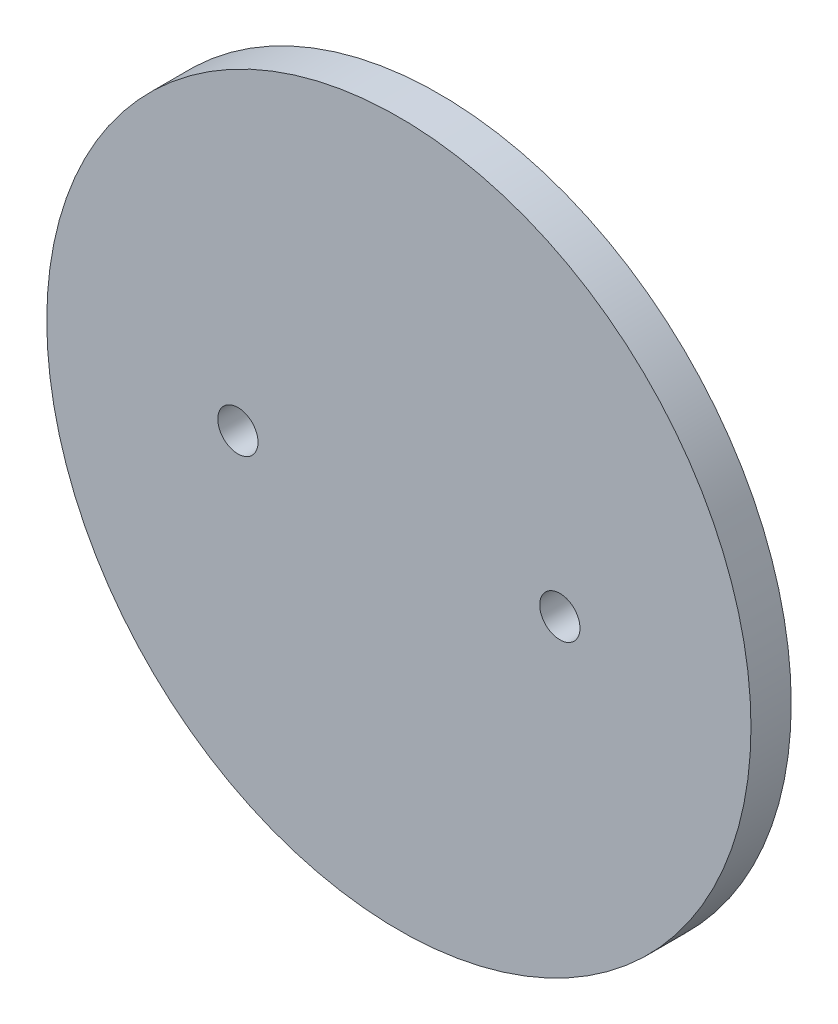
from build123d import *

# Parameters (mm, degrees)
SKETCH1_R           = 22.225
BOSS_EXTRUDE1_DEPTH = 2.54
CUT_EXTRUDE1_DEPTH  = 3.54


with BuildPart() as part:
    # Sketch1 → Boss-Extrude1 (new body)
    with BuildSketch(Plane.XY):
        Circle(SKETCH1_R)
    extrude(amount=BOSS_EXTRUDE1_DEPTH)

    # Sketch2 → Cut-Extrude1 (cut, through all)
    with BuildSketch(Plane.XY.offset(2.54)):
        with BuildLine():
            ThreePointArc((-8.89, 0), (-10.16, 1.27), (-11.43, 0))
            Line((-11.43, 0), (-8.89, 0))
        make_face()
        with BuildLine():
            Line((-8.89, 0), (-11.43, 0))
            ThreePointArc((-11.43, 0), (-10.16, -1.27), (-8.89, 0))
        make_face()
        with BuildLine():
            ThreePointArc((11.43, 0), (10.16, 1.27), (8.89, 0))
            Line((8.89, 0), (11.43, 0))
        make_face()
        with BuildLine():
            Line((11.43, 0), (8.89, 0))
            ThreePointArc((8.89, 0), (10.16, -1.27), (11.43, 0))
        make_face()
    extrude(amount=-CUT_EXTRUDE1_DEPTH, mode=Mode.SUBTRACT)


solid = part.part
